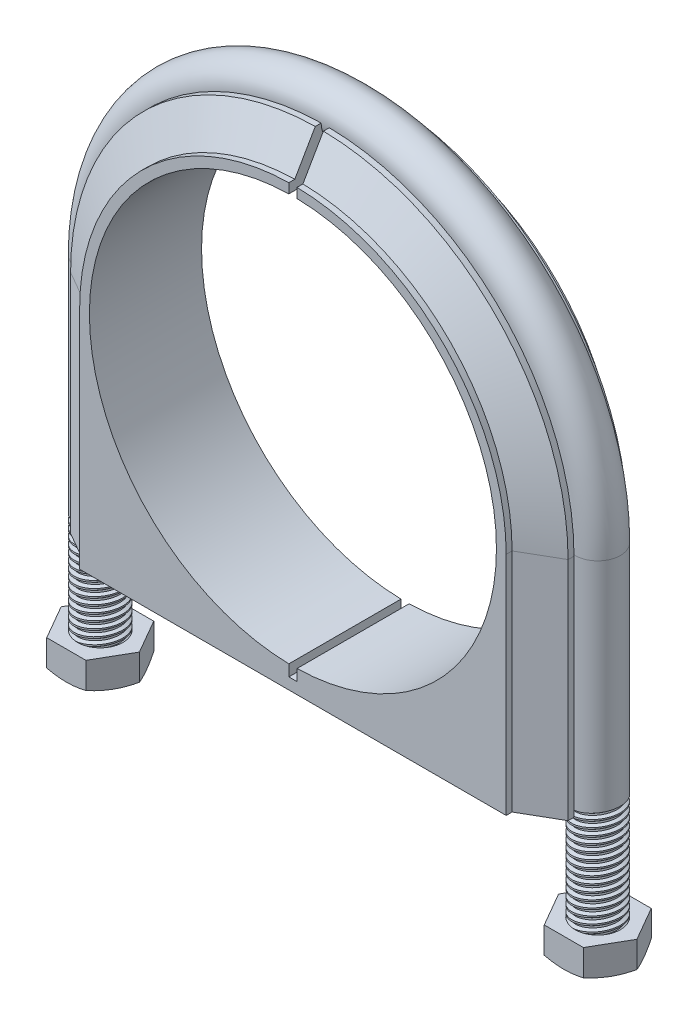
from build123d import *

# Parameters (mm, degrees)
SKETCH2_R               = 6.35
LPATTERN2_COUNT         = 2
LPATTERN2_PITCH         = 139.7
LPATTERN2_COUNT_DIR2    = 19
LPATTERN2_PITCH_DIR2    = 1.953846154
EXTRUDE2_DEPTH          = 15.748
EXTRUDE2_DEPTH_BACK     = 15.748
CUT_EXTRUDE1_DEPTH      = 16.748
CUT_EXTRUDE1_DEPTH_BACK = 16.748
SKETCH7_R               = 6.36
EXTRUDE1_DEPTH          = 34.798
CHAMFER1_SIZE           = 0.195384615
SKETCH13_R              = 6.36
CUT_EXTRUDE2_DEPTH      = 27.5
LPATTERN3_COUNT         = 2
LPATTERN3_PITCH         = 139.7


with BuildPart() as part:
    # Sweep1: sweep along a path in Sketch1
    with BuildLine(Plane.XY) as sweep1_path:
        Line((-63.5, 0), (-63.5, 99.06))
        ThreePointArc((-63.5, 99.06), (0, 162.56), (63.5, 99.06))
        Line((63.5, 99.06), (63.5, 0))
    # Sketch2 → Sweep1 (sweep)
    with BuildSketch(Plane(origin=(0, 0, 0), x_dir=(1, 0, 0), z_dir=(0, 1, 0))):
        with Locations((-69.85, 0)):
            Circle(SKETCH2_R)
    sweep(path=sweep1_path.line)

    # Sketch4 → Cut-Revolve1 (revolve, cut)
    with BuildSketch(Plane.XY):
        Polygon((-63.5, 38.1), (-64.452410131, 37.335714936), (-64.378136045, 36.852933376), (-63.240040698, 36.41026454), align=None)
    cut_revolve1 = revolve(axis=Axis((-69.56664805, 34.416424647, 0), (-0.152057184, 0.988371698, 0)), mode=Mode.SUBTRACT)

    # Sketch5 → Cut-Revolve2 (revolve, cut)
    with BuildSketch(Plane.XY):
        Polygon((-63.5, 0), (-63.5, 2.042450117), (-64.452410131, 0), align=None)
    revolve(axis=Axis((-69.85, -0.740049361, 0), (0, 1, 0)), mode=Mode.SUBTRACT)

    # Sketch6 → Cut-Revolve3 (revolve, cut)
    with BuildSketch(Plane.XY):
        Polygon((63.5, 0), (64.452410131, 0), (63.5, 2.042450117), align=None)
    revolve(axis=Axis((69.85, 2.702585519, 0), (0, -1, 0)), mode=Mode.SUBTRACT)

    # LPattern2: Cut-Revolve1 2 × 19
    with Locations(*[(i * LPATTERN2_PITCH, -j * LPATTERN2_PITCH_DIR2, 0) for i in range(LPATTERN2_COUNT) for j in range(LPATTERN2_COUNT_DIR2) if (i, j) != (0, 0)]):
        add(cut_revolve1, mode=Mode.SUBTRACT)


with BuildPart() as body_2:
    # Sweep2: sweep along a path in Sketch9
    with BuildLine(Plane.XY) as sweep2_path:
        Line((63.5, 35.56), (63.5, 99.06))
        ThreePointArc((63.5, 99.06), (0, 162.56), (-63.5, 99.06))
        Line((-63.5, 99.06), (-63.5, 35.56))
    # Sketch10 → Sweep2 (sweep)
    with BuildSketch(Plane(origin=(0, 35.56, 0), x_dir=(-1, 0, 0), z_dir=(0, 1, 0))):
        with BuildLine():
            Line((69.85, 6.6675), (69.85, 8.33032357))
            Line((69.85, 8.33032357), (59.882302456, 14.08517643))
            Line((59.882302456, 14.08517643), (59.882302456, 15.748))
            Line((59.882302456, 15.748), (3.175, 15.748))
            Line((3.175, 15.748), (3.175, -15.748))
            Line((3.175, -15.748), (59.882302456, -15.748))
            Line((59.882302456, -15.748), (59.882302456, -14.08517643))
            Line((59.882302456, -14.08517643), (69.85, -8.33032357))
            Line((69.85, -8.33032357), (69.85, -6.6675))
            ThreePointArc((69.85, -6.6675), (63.1825, 0), (69.85, 6.6675))
        make_face()
    sweep(path=sweep2_path.line)

    # Sketch11 → Extrude2 (add, two sides)
    with BuildSketch(Plane.XY) as extrude2_sk:
        with BuildLine():
            Line((3.175, 35.56), (-3.175, 35.56))
            Line((-3.175, 35.56), (-3.175, 99.06))
            ThreePointArc((-3.175, 99.06), (0, 102.235), (3.175, 99.06))
            Line((3.175, 99.06), (3.175, 35.56))
        make_face()
    extrude(amount=EXTRUDE2_DEPTH)
    extrude(extrude2_sk.sketch, amount=-EXTRUDE2_DEPTH_BACK)

    # Sketch12 → Cut-Extrude1 (cut, two sides)
    with BuildSketch(Plane.XY) as cut_extrude1_sk:
        with BuildLine():
            Line((-1.143, 168.91), (1.143, 168.91))
            Line((1.143, 168.91), (1.143, 156.198568857))
            ThreePointArc((1.143, 156.198568857), (57.15, 99.06), (1.143, 41.921431143))
            Line((1.143, 41.921431143), (1.143, 38.740715572))
            Line((1.143, 38.740715572), (-1.143, 38.740715572))
            Line((-1.143, 38.740715572), (-1.143, 41.921431143))
            ThreePointArc((-1.143, 41.921431143), (-57.15, 99.06), (-1.143, 156.198568857))
            Line((-1.143, 156.198568857), (-1.143, 168.91))
        make_face()
    extrude(amount=CUT_EXTRUDE1_DEPTH, mode=Mode.SUBTRACT)
    extrude(cut_extrude1_sk.sketch, amount=-CUT_EXTRUDE1_DEPTH_BACK, mode=Mode.SUBTRACT)


with BuildPart() as body_3:
    # Sketch7 → Extrude1 (new body)
    with BuildSketch(Plane.XZ.offset(-34.798)):
        Polygon((-58.851477372, 0), (-64.350738686, 9.525), (-75.349261314, 9.525), (-80.848522628, 0), (-75.349261314, -9.525), (-64.350738686, -9.525), align=None)
        with Locations((-69.85, 0)):
            Circle(SKETCH7_R, mode=Mode.SUBTRACT)
    extrude(amount=EXTRUDE1_DEPTH)

    # Sketch8 → Cut-Revolve4 (revolve, cut)
    with BuildSketch(Plane.XY):
        Polygon((-60.325, 34.798), (-58.851477372, 34.110885114), (-58.851477372, 34.798), align=None)
        Polygon((-58.851477372, 0.687114886), (-60.325, 0), (-58.851477372, 0), align=None)
    revolve(axis=Axis((-69.85, 13.551526713, 0), (0, -1, 0)), mode=Mode.SUBTRACT)

    # Chamfer1
    chamfer1_edges = [body_3.edges().sort_by_distance(p)[0] for p in [
        (-76.21, 0, 0),
        (-76.21, 34.798, 0),
    ]]
    chamfer(chamfer1_edges, length=CHAMFER1_SIZE)

    # Sketch13 → Cut-Extrude2 (cut)
    with BuildSketch(Plane.XZ.offset(-35.56)):
        Polygon((-64.350738686, 9.525), (-69.85, 9.525), (-75.349261314, 9.525), (-78.098891971, 4.7625), (-80.848522628, 0), (-78.098891971, -4.7625), (-75.349261314, -9.525), (-69.85, -9.525), (-64.350738686, -9.525), (-61.601108029, -4.7625), (-58.851477372, 0), (-61.601108029, 4.7625), align=None)
        with Locations((-69.85, 0)):
            Circle(SKETCH13_R, mode=Mode.SUBTRACT)
    extrude(amount=CUT_EXTRUDE2_DEPTH, mode=Mode.SUBTRACT)


with BuildPart() as lpattern3_1:
    # LPattern3: pattern copy
    add(body_3.part.moved(Location(Vector(1, 0, 0) * (1 * LPATTERN3_PITCH))))


solid = Compound([part.part, body_2.part, body_3.part, lpattern3_1.part])
